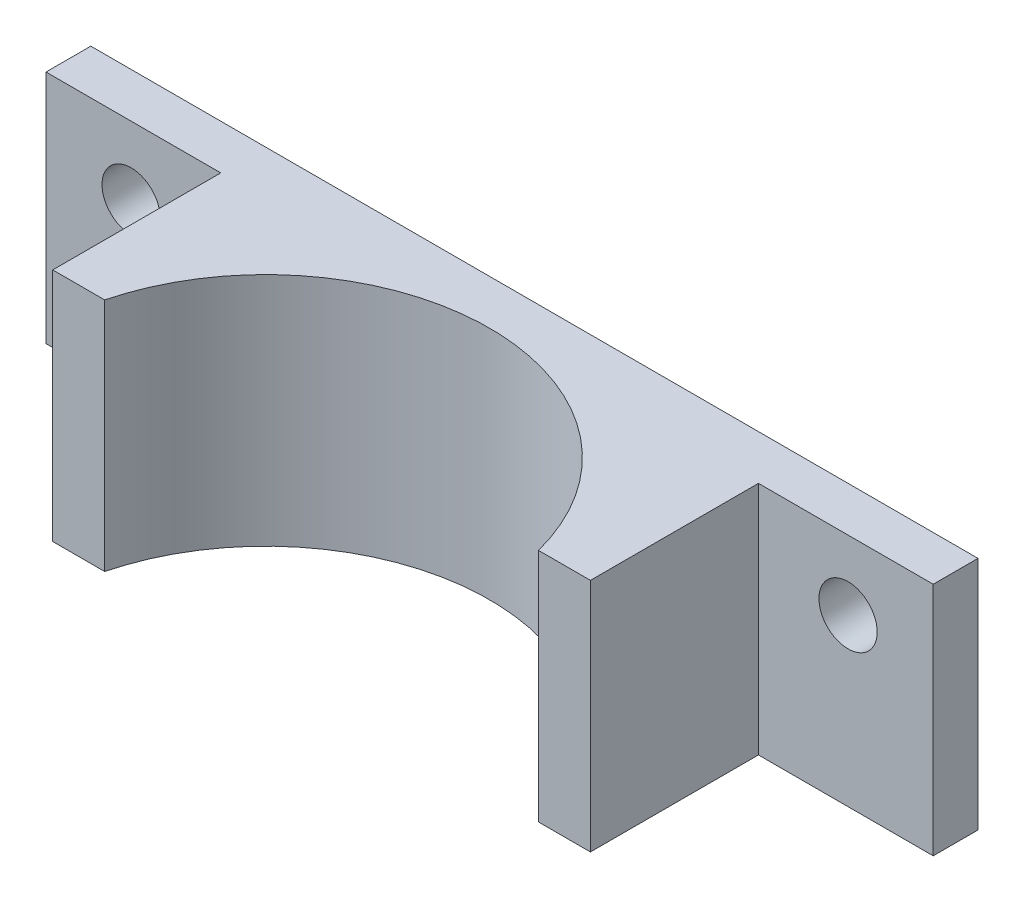
from build123d import *

# Parameters (mm, degrees)
SKETCH1_W           = 100.584
SKETCH1_H           = 53.34
SKETCH1_R           = 3.302
BOSS_EXTRUDE2_DEPTH = 5.08
SKETCH5_W           = 60.96
SKETCH5_H           = 53.34
BOSS_EXTRUDE3_DEPTH = 19.05
CUT_EXTRUDE4_REACH  = 55.34
SKETCH6_R           = 25.4
SKETCH7_W           = 100.584
SKETCH7_H           = 26.67
CUT_EXTRUDE5_DEPTH  = 25.13


with BuildPart() as part:
    # Sketch1 → Boss-Extrude2 (new body)
    with BuildSketch(Plane.XY):
        with Locations((-9.978006062, 1.929359203)):
            Rectangle(SKETCH1_W, SKETCH1_H)
        with Locations((30.661993938, 20.725359203)):
            Circle(SKETCH1_R, mode=Mode.SUBTRACT)
        with Locations((30.661993938, -16.866640797)):
            Circle(SKETCH1_R, mode=Mode.SUBTRACT)
        with Locations((-50.618006062, 20.725359203)):
            Circle(SKETCH1_R, mode=Mode.SUBTRACT)
        with Locations((-50.618006062, -16.866640797)):
            Circle(SKETCH1_R, mode=Mode.SUBTRACT)
    extrude(amount=BOSS_EXTRUDE2_DEPTH)

    # Sketch5 → Boss-Extrude3 (add)
    with BuildSketch(Plane.XY.offset(5.08)):
        with Locations((-9.978006062, 1.929359203)):
            Rectangle(SKETCH5_W, SKETCH5_H)
    extrude(amount=BOSS_EXTRUDE3_DEPTH)

    # Sketch6 → Cut-Extrude4 (cut, up to next)
    with BuildSketch(Plane.XZ.offset(24.740640797), mode=Mode.PRIVATE) as cut_extrude4_sk1:
        with Locations((-9.978006062, 30.48)):
            Circle(SKETCH6_R)
    cut_extrude4_tool1 = extrude(cut_extrude4_sk1.sketch, amount=-CUT_EXTRUDE4_REACH, mode=Mode.PRIVATE) & part.part
    add(cut_extrude4_tool1.solids().sort_by_distance((-9.978006, -24.740641, 30.48))[0], mode=Mode.SUBTRACT)

    # Sketch7 → Cut-Extrude5 (cut, through all)
    with BuildSketch(Plane(origin=(0, 0, 0), x_dir=(-1, 0, 0), z_dir=(0, 0, -1))):
        with Locations((9.978006062, -11.405640797)):
            Rectangle(SKETCH7_W, SKETCH7_H)
    extrude(amount=-CUT_EXTRUDE5_DEPTH, mode=Mode.SUBTRACT)


solid = part.part
